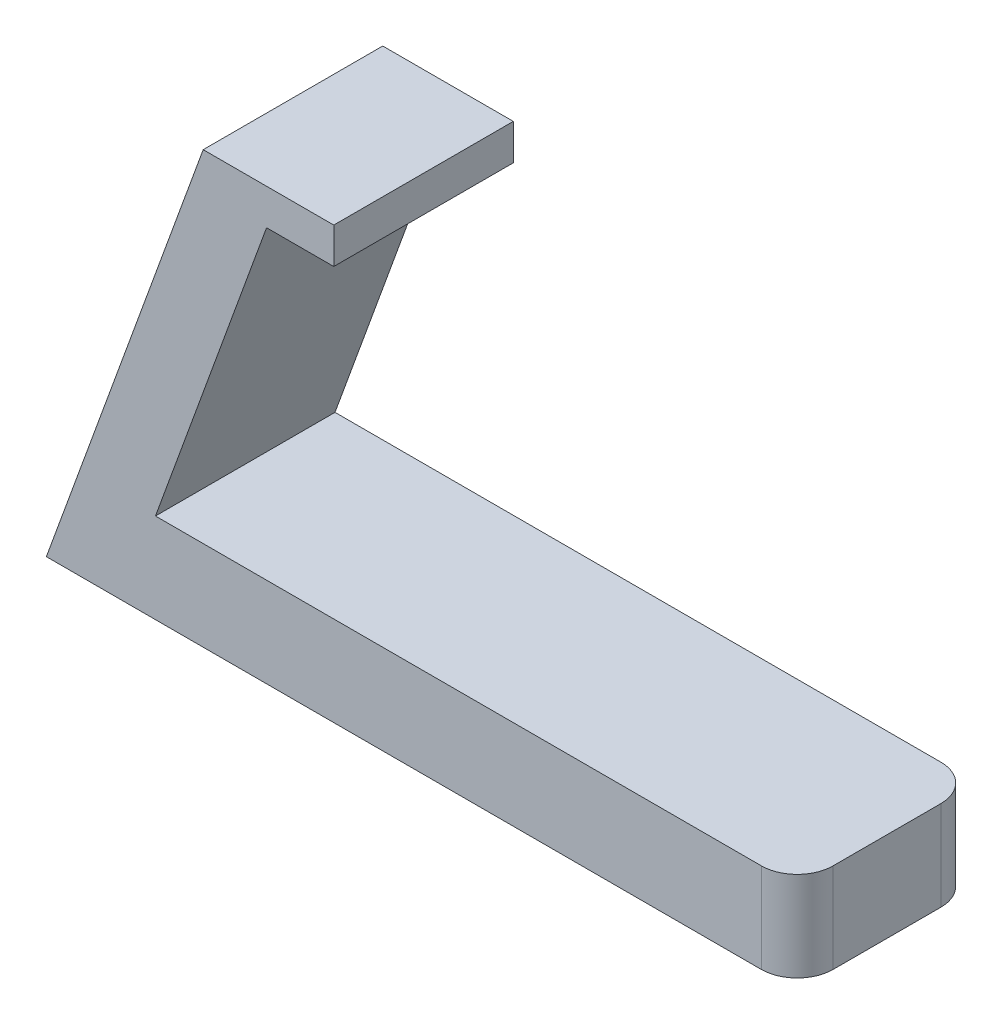
from build123d import *

# Parameters (mm, degrees)
SKETCH1_W           = 50.8
SKETCH1_H           = 12.7
BOSS_EXTRUDE1_DEPTH = 6.35
FILLET1_R           = 2.54
BOSS_EXTRUDE2_DEPTH = 12.7
BOSS_EXTRUDE3_DEPTH = 12.7


with BuildPart() as part:
    # Sketch1 → Boss-Extrude1 (new body)
    with BuildSketch(Plane(origin=(0, 0, 0), x_dir=(1, 0, 0), z_dir=(0, 1, 0))):
        with Locations((25.4, 6.35)):
            Rectangle(SKETCH1_W, SKETCH1_H)
    extrude(amount=BOSS_EXTRUDE1_DEPTH)

    # Fillet1
    fillet1_edges = [part.edges().sort_by_distance(p)[0] for p in [
        (50.8, 3.175, -12.7),
        (50.8, 3.175, 0),
    ]]
    fillet(fillet1_edges, radius=FILLET1_R)

    # Sketch3 → Boss-Extrude2 (add)
    with BuildSketch(Plane.XY):
        Polygon((-2.311210988, 0), (7.858117358, 27.94), (13.264140442, 27.94), (3.094812097, 0), align=None)
    extrude(amount=-BOSS_EXTRUDE2_DEPTH)

    # Sketch4 → Boss-Extrude3 (add)
    with BuildSketch(Plane.XY):
        Polygon((7.858117358, 27.94), (18.018117358, 27.94), (18.018117358, 30.48), (8.782601753, 30.48), align=None)
    extrude(amount=-BOSS_EXTRUDE3_DEPTH)


solid = part.part
